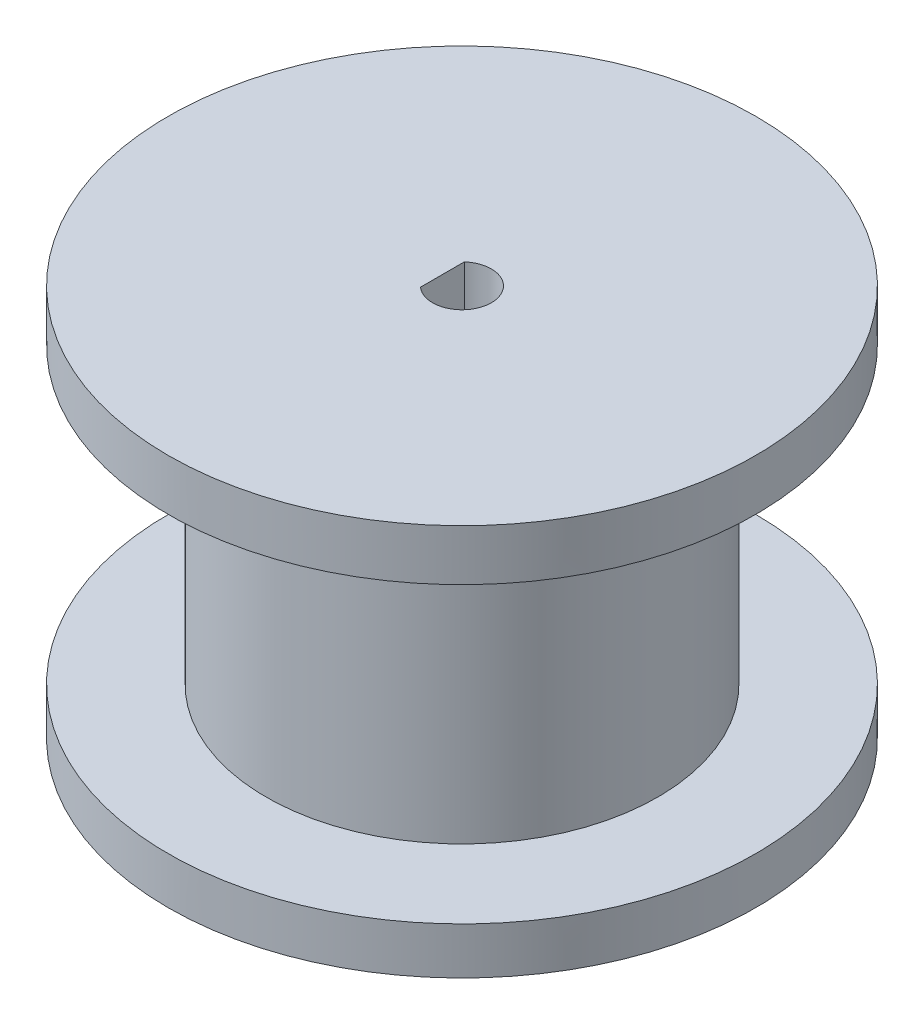
from build123d import *

# Parameters (mm, degrees)
SKETCH_1_R      = 15
EXTRUDE_1_DEPTH = 20
SKETCH_2_W      = 5
SKETCH_2_H      = 15


with BuildPart() as part:
    # 草图1 → 凸台-拉伸1 (new body)
    with BuildSketch(Plane(origin=(0, 0, 0), x_dir=(1, 0, 0), z_dir=(0, 1, 0))):
        Circle(SKETCH_1_R)
        with BuildLine():
            Line((-1, -1.118033989), (-1, 1.118033989))
            ThreePointArc((-1, 1.118033989), (1.5, 0), (-1, -1.118033989))
        make_face(mode=Mode.SUBTRACT)
    extrude(amount=EXTRUDE_1_DEPTH)

    # 草图2 → 切除-旋转1 (revolve, cut)
    with BuildSketch(Plane.XY):
        with Locations((12.5, 9.892021361)):
            Rectangle(SKETCH_2_W, SKETCH_2_H)
    revolve(axis=Axis((0, 0, 0), (0, 1, 0)), mode=Mode.SUBTRACT)


solid = part.part
